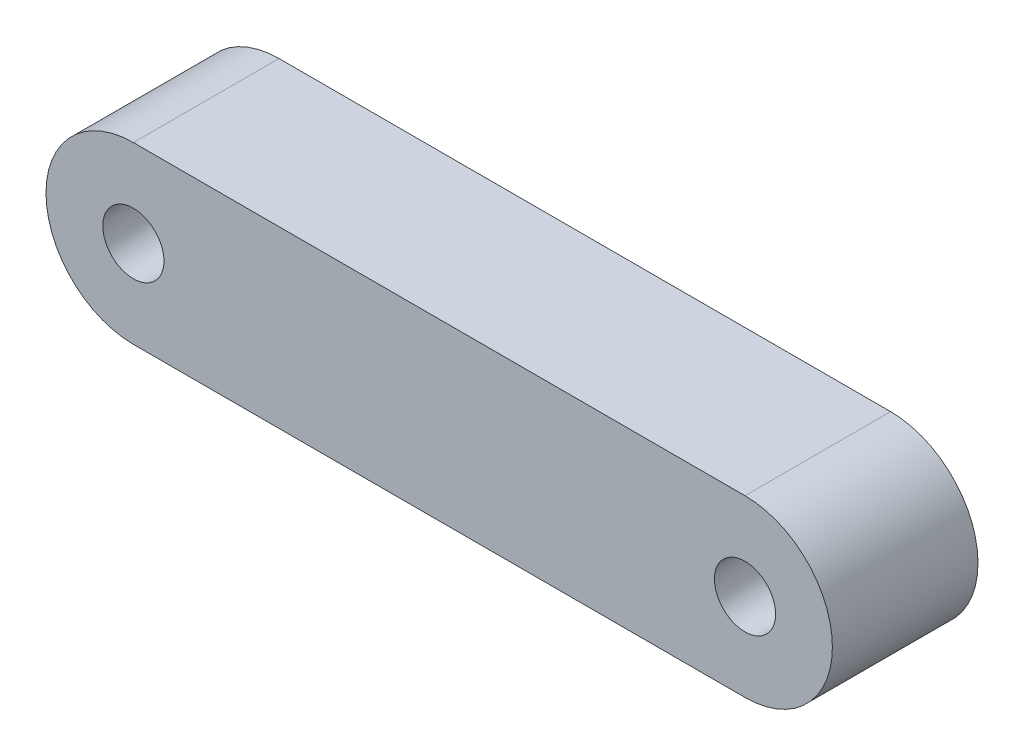
from build123d import *

# Parameters (mm, degrees)
SKETCH1_R           = 1.75
BOSS_EXTRUDE1_DEPTH = 8.333333333


with BuildPart() as part:
    # Sketch1 → Boss-Extrude1 (new body)
    with BuildSketch(Plane.XY):
        with BuildLine():
            Line((0, 5), (35, 5))
            ThreePointArc((35, 5), (40, 0), (35, -5))
            Line((35, -5), (0, -5))
            ThreePointArc((0, -5), (-5, 0), (0, 5))
        make_face()
        Circle(SKETCH1_R, mode=Mode.SUBTRACT)
        with Locations((35, 0)):
            Circle(SKETCH1_R, mode=Mode.SUBTRACT)
    extrude(amount=BOSS_EXTRUDE1_DEPTH)


solid = part.part
